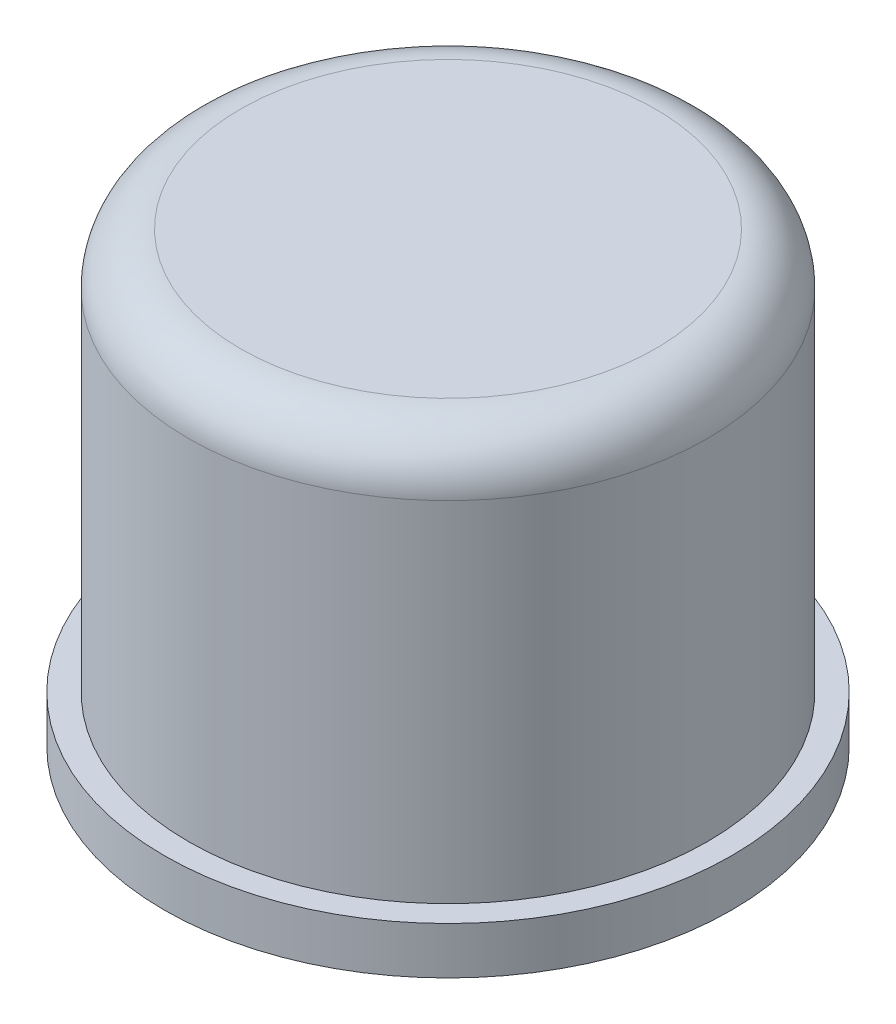
from build123d import *

# Parameters (mm, degrees)
SKETCH2_R           = 1100
BOSS_EXTRUDE1_DEPTH = 1700
FILLET1_R           = 220
SKETCH3_R           = 1202.889766508
BOSS_EXTRUDE2_DEPTH = 200


with BuildPart() as part:
    # Sketch2 → Boss-Extrude1 (new body)
    with BuildSketch(Plane(origin=(0, 0, 0), x_dir=(1, 0, 0), z_dir=(0, 1, 0))):
        Circle(SKETCH2_R)
    extrude(amount=BOSS_EXTRUDE1_DEPTH)

    # Fillet1
    fillet1_edges = [part.edges().sort_by_distance(p)[0] for p in [
        (-1100, 1700, 0),
    ]]
    fillet(fillet1_edges, radius=FILLET1_R)

    # Sketch3 → Boss-Extrude2 (add)
    with BuildSketch(Plane.XZ):
        Circle(SKETCH3_R)
    extrude(amount=BOSS_EXTRUDE2_DEPTH)


solid = part.part
